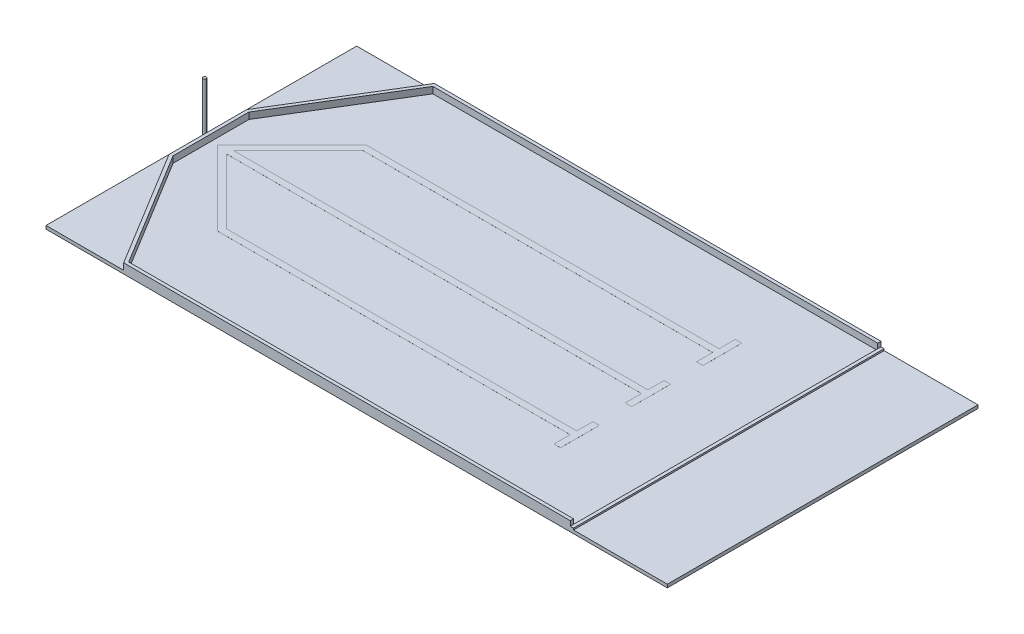
from build123d import *

# Parameters (mm, degrees)
SKETCH1_W             = 2438.4
SKETCH1_H             = 1219.2
BASE_DEPTH            = 12.7
OUTSIDE_WALLS_DEPTH   = 25.4
SKETCH3_W             = 12.7
SKETCH3_H             = 1219.2
FRONT_WALL_DEPTH      = 6.35
TAPE_DEPTH            = 0.1
SKETCH5_R             = 6.35
F_10KHZ_EMITTER_DEPTH = 203.2


with BuildPart() as part:
    # Sketch1 → Base (new body)
    with BuildSketch(Plane(origin=(0, 0, 0), x_dir=(1, 0, 0), z_dir=(0, 1, 0))):
        with Locations((1219.2, -609.6)):
            Rectangle(SKETCH1_W, SKETCH1_H)
    extrude(amount=BASE_DEPTH)

    # Sketch2 → Outside Walls (add)
    with BuildSketch(Plane(origin=(0, 12.7, 0), x_dir=(1, 0, 0), z_dir=(0, 1, 0))):
        Polygon((304.8, 0), (25.4, -457.2), (25.4, -762), (304.8, -1219.2), (2057.4, -1219.2), (2057.4, -1206.5), (311.922599639, -1206.5), (38.1, -758.426655137), (38.1, -460.773344863), (311.922599639, -12.7), (2057.4, -12.7), (2057.4, 0), align=None)
    extrude(amount=OUTSIDE_WALLS_DEPTH)

    # Sketch3 → Front Wall (add)
    with BuildSketch(Plane(origin=(0, 12.7, 0), x_dir=(1, 0, 0), z_dir=(0, 1, 0))):
        with Locations((2063.75, -609.6)):
            Rectangle(SKETCH3_W, SKETCH3_H)
    extrude(amount=FRONT_WALL_DEPTH)

    # Sketch4 → Tape (add)
    with BuildSketch(Plane(origin=(0, 12.7, 0), x_dir=(1, 0, 0), z_dir=(0, 1, 0))):
        Polygon((63.5, -609.6), (355.6, -901.7), (1739.9, -901.7), (1739.9, -965.2), (1765.3, -965.2), (1765.3, -812.8), (1739.9, -812.8), (1739.9, -876.3), (366.121024484, -876.3), (112.121024484, -622.3), (1739.9, -622.3), (1739.9, -685.8), (1765.3, -685.8), (1765.3, -533.4), (1739.9, -533.4), (1739.9, -596.9), (112.121024484, -596.9), (366.121024484, -342.9), (1739.9, -342.9), (1739.9, -406.4), (1765.3, -406.4), (1765.3, -254), (1739.9, -254), (1739.9, -317.5), (355.6, -317.5), align=None)
    extrude(amount=TAPE_DEPTH)

    # Sketch5 → 10kHz Emitter (add)
    with BuildSketch(Plane(origin=(0, 12.7, 0), x_dir=(1, 0, 0), z_dir=(0, 1, 0))):
        with Locations((12.7, -609.6)):
            Circle(SKETCH5_R)
    extrude(amount=F_10KHZ_EMITTER_DEPTH)


solid = part.part
